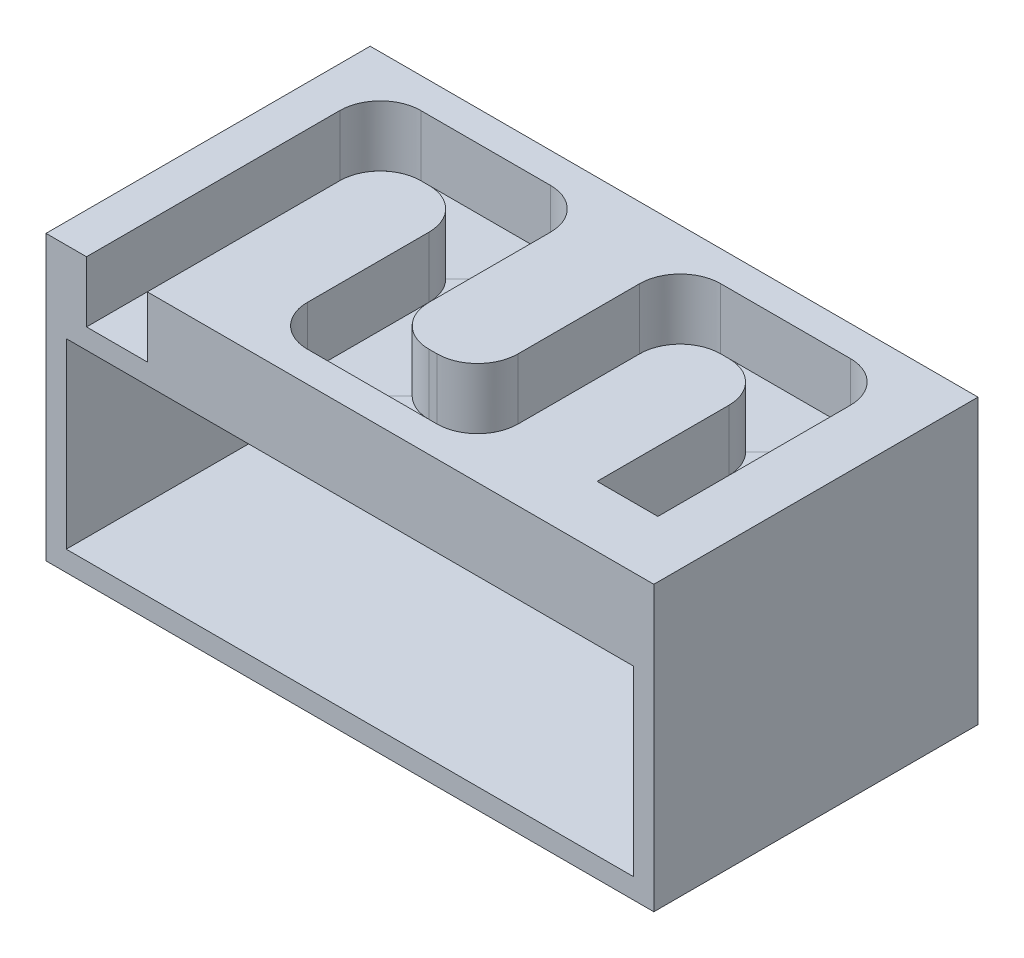
from build123d import *

# Parameters (mm, degrees)
SKETCH1_W                 = 150
SKETCH1_H                 = 80
BOSS_EXTRUDE1_DEPTH       = 70
SHELL1_T                  = -5
SHELL1_THICKNESS_2_FACE_W = 75
SHELL1_THICKNESS_2_FACE_H = 140
SHELL1_THICKNESS_2_DEPTH  = 15
SKETCH2_W                 = 15
SKETCH2_H                 = 15
FILLET1_R                 = 10


with BuildPart() as part:
    # Sketch1 → Boss-Extrude1 (new body)
    with BuildSketch(Plane(origin=(0, 0, 0), x_dir=(1, 0, 0), z_dir=(0, 1, 0))):
        with Locations((75, 40)):
            Rectangle(SKETCH1_W, SKETCH1_H)
    extrude(amount=BOSS_EXTRUDE1_DEPTH)

    # Shell1
    shell1_openings = [part.faces().sort_by_distance(p)[0] for p in [
        (75, 35, 0),
    ]]
    offset(amount=SHELL1_T, openings=shell1_openings, kind=Kind.INTERSECTION)

    # Shell1 thickness 2 face (on inner face of the shell) → Shell1 thickness 2 (add)
    with BuildSketch(Plane(origin=(75, 65, -37.5), x_dir=(0, 0, 1), z_dir=(0, 1, 0))):
        Rectangle(SHELL1_THICKNESS_2_FACE_W, SHELL1_THICKNESS_2_FACE_H)
    extrude(amount=-SHELL1_THICKNESS_2_DEPTH)

    # Cut-Sweep1: sweep along a path in Sketch3
    with BuildLine(Plane(origin=(0, 70, 0), x_dir=(1, 0, 0), z_dir=(0, 1, 0))) as cut_sweep1_path:
        Line((17.5, 0), (17.5, 65))
        Line((17.5, 65), (54.5, 65))
        Line((54.5, 65), (54.5, 15))
        Line((54.5, 15), (91.5, 15))
        Line((91.5, 15), (91.5, 65))
        Line((91.5, 65), (128.5, 65))
        Line((128.5, 65), (128.5, 15))
    # Sketch2 → Cut-Sweep1 (sweep, cut)
    with BuildSketch(Plane.XY):
        with Locations((17.5, 62.5)):
            Rectangle(SKETCH2_W, SKETCH2_H)
    sweep(path=cut_sweep1_path.line, transition=Transition.RIGHT, mode=Mode.SUBTRACT)

    # Fillet1
    fillet1_edges = [part.edges().sort_by_distance(p)[0] for p in [
        (121, 62.5, -57.5),
        (136, 62.5, -72.5),
        (84, 62.5, -72.5),
        (99, 62.5, -57.5),
        (84, 62.5, -22.5),
        (99, 62.5, -7.5),
        (62, 62.5, -22.5),
        (47, 62.5, -7.5),
        (62, 62.5, -72.5),
        (47, 62.5, -57.5),
        (10, 62.5, -72.5),
        (25, 62.5, -57.5),
    ]]
    fillet(fillet1_edges, radius=FILLET1_R)


solid = part.part
